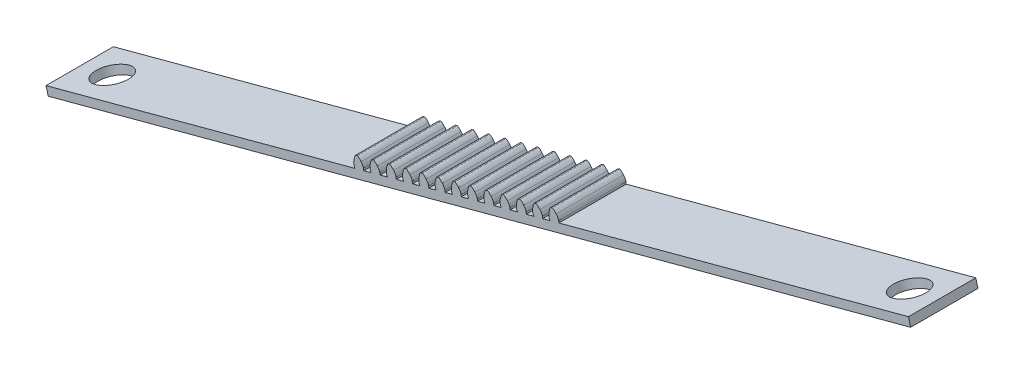
from build123d import *

# Parameters (mm, degrees)
BOSS_EXTRUDE1_DEPTH = 25.4
SKETCH2_W           = 25.4
SKETCH2_H           = 3.175
BOSS_EXTRUDE2_DEPTH = 57.15
SKETCH3_W           = 25.4
SKETCH3_H           = 3.175
BOSS_EXTRUDE3_DEPTH = 53.975
SKETCH4_R           = 6.35
CUT_EXTRUDE3_DEPTH  = 25.4
SKETCH5_R           = 6.35
CUT_EXTRUDE4_DEPTH  = 10


with BuildPart() as part:
    # Sketch1 → Boss-Extrude1 (new body)
    with BuildSketch(Plane.XY):
        Polygon((44.647261736, 20.714486461), (-13.352958173, 5.173374375), (-16.689028233, 4.279477097), (-15.867277765, 1.212662598), (202.166329374, 59.634591554), (201.344578906, 62.701406052), (121.586879759, 41.330394976), (118.2508097, 40.436497698), (115.453250762, 39.68689404), (112.117180703, 38.792996761), (109.319621765, 38.043393103), (105.983551706, 37.149495825), (103.185992768, 36.399892167), (99.849922709, 35.505994888), (97.052363772, 34.75639123), (93.716293712, 33.862493952), (90.918734775, 33.112890294), (87.582664715, 32.218993016), (84.785105778, 31.469389357), (81.449035718, 30.575492079), (78.651476781, 29.825888421), (75.315406721, 28.931991143), (72.517847784, 28.182387485), (69.181777724, 27.288490206), (66.384218787, 26.538886548), (63.048148727, 25.64498927), (60.25058979, 24.895385612), (56.91451973, 24.001488334), (54.116960793, 23.251884675), (50.780890733, 22.357987397), (47.983331796, 21.608383739), align=None)
        with BuildLine():
            Line((44.348064563, 21.379688114), (44.647261736, 20.714486461))
            Line((44.647261736, 20.714486461), (47.983331796, 21.608383739))
            Line((47.983331796, 21.608383739), (47.909843322, 22.334063856))
            add(Edge.make_bspline(
                [(47.909843322, 22.334063856), (47.656461382, 23.298010334), (46.99176643, 24.051815986)],
                knots=[0, 0, 0, 1, 1, 1], degree=2))
            add(Edge.make_bspline(
                [(46.99176643, 24.051815986), (46.671641431, 24.436486873), (46.198202162, 24.922805329), (45.688546167, 25.305711494), (45.505990595, 25.264278727)],
                knots=[0, 0, 0, 0, 0.77483603, 1, 1, 1, 1], degree=3))
            Line((45.505990595, 25.264278727), (44.964754656, 25.119254995))
            add(Edge.make_bspline(
                [(44.28426641, 23.326343542), (44.369167347, 23.819540802), (44.536018554, 24.477424573), (44.78594051, 25.063859037), (44.964754656, 25.119254995)],
                knots=[0, 0, 0, 0, 0.77483603, 1, 1, 1, 1], degree=3))
            add(Edge.make_bspline(
                [(44.348064563, 21.379688114), (44.085526521, 22.341181222), (44.28426641, 23.326343542)],
                knots=[0, 0, 0, 1, 1, 1], degree=2))
        make_face()
        with BuildLine():
            Line((50.48169356, 23.02318905), (50.780890733, 22.357987397))
            Line((50.780890733, 22.357987397), (54.116960793, 23.251884675))
            Line((54.116960793, 23.251884675), (54.043472319, 23.977564792))
            add(Edge.make_bspline(
                [(54.043472319, 23.977564792), (53.790090379, 24.94151127), (53.125395427, 25.695316922)],
                knots=[0, 0, 0, 1, 1, 1], degree=2))
            add(Edge.make_bspline(
                [(53.125395427, 25.695316922), (52.805270428, 26.079987809), (52.331831159, 26.566306265), (51.822175164, 26.949212431), (51.639619592, 26.907779664)],
                knots=[0, 0, 0, 0, 0.77483603, 1, 1, 1, 1], degree=3))
            Line((51.639619592, 26.907779664), (51.098383653, 26.762755931))
            add(Edge.make_bspline(
                [(50.417895407, 24.969844478), (50.502796344, 25.463041738), (50.669647551, 26.12092551), (50.919569507, 26.707359974), (51.098383653, 26.762755931)],
                knots=[0, 0, 0, 0, 0.77483603, 1, 1, 1, 1], degree=3))
            add(Edge.make_bspline(
                [(50.48169356, 23.02318905), (50.219155518, 23.984682158), (50.417895407, 24.969844478)],
                knots=[0, 0, 0, 1, 1, 1], degree=2))
        make_face()
        with BuildLine():
            Line((118.2508097, 40.436497698), (121.586879759, 41.330394976))
            Line((121.586879759, 41.330394976), (121.513391285, 42.056075093))
            add(Edge.make_bspline(
                [(121.513391285, 42.056075093), (121.260009346, 43.020021571), (120.595314393, 43.773827223)],
                knots=[0, 0, 0, 1, 1, 1], degree=2))
            add(Edge.make_bspline(
                [(120.595314393, 43.773827223), (120.275189395, 44.15849811), (119.801750125, 44.644816566), (119.29209413, 45.027722731), (119.109538558, 44.986289964)],
                knots=[0, 0, 0, 0, 0.77483603, 1, 1, 1, 1], degree=3))
            Line((119.109538558, 44.986289964), (118.568302619, 44.841266231))
            add(Edge.make_bspline(
                [(117.887814373, 43.048354779), (117.972715311, 43.541552038), (118.139566517, 44.19943581), (118.389488473, 44.785870274), (118.568302619, 44.841266231)],
                knots=[0, 0, 0, 0, 0.77483603, 1, 1, 1, 1], degree=3))
            add(Edge.make_bspline(
                [(117.951612527, 41.101699351), (117.689074484, 42.063192458), (117.887814373, 43.048354779)],
                knots=[0, 0, 0, 1, 1, 1], degree=2))
            Line((117.951612527, 41.101699351), (118.2508097, 40.436497698))
        make_face()
        with BuildLine():
            Line((56.615322557, 24.666689987), (56.91451973, 24.001488334))
            Line((56.91451973, 24.001488334), (60.25058979, 24.895385612))
            Line((60.25058979, 24.895385612), (60.177101316, 25.621065729))
            add(Edge.make_bspline(
                [(60.177101316, 25.621065729), (59.923719376, 26.585012207), (59.259024424, 27.338817859)],
                knots=[0, 0, 0, 1, 1, 1], degree=2))
            add(Edge.make_bspline(
                [(59.259024424, 27.338817859), (58.938899425, 27.723488746), (58.465460156, 28.209807202), (57.955804161, 28.592713367), (57.773248589, 28.5512806)],
                knots=[0, 0, 0, 0, 0.77483603, 1, 1, 1, 1], degree=3))
            Line((57.773248589, 28.5512806), (57.23201265, 28.406256867))
            add(Edge.make_bspline(
                [(56.551524404, 26.613345415), (56.636425341, 27.106542674), (56.803276548, 27.764426446), (57.053198504, 28.35086091), (57.23201265, 28.406256867)],
                knots=[0, 0, 0, 0, 0.77483603, 1, 1, 1, 1], degree=3))
            add(Edge.make_bspline(
                [(56.615322557, 24.666689987), (56.352784515, 25.628183094), (56.551524404, 26.613345415)],
                knots=[0, 0, 0, 1, 1, 1], degree=2))
        make_face()
        with BuildLine():
            Line((112.117180703, 38.792996761), (115.453250762, 39.68689404))
            Line((115.453250762, 39.686894039), (115.379762288, 40.412574156))
            add(Edge.make_bspline(
                [(115.379762288, 40.412574156), (115.126380349, 41.376520634), (114.461685396, 42.130326286)],
                knots=[0, 0, 0, 1, 1, 1], degree=2))
            add(Edge.make_bspline(
                [(114.461685396, 42.130326286), (114.141560398, 42.514997173), (113.668121128, 43.001315629), (113.158465133, 43.384221795), (112.975909561, 43.342789028)],
                knots=[0, 0, 0, 0, 0.77483603, 1, 1, 1, 1], degree=3))
            Line((112.975909561, 43.342789028), (112.434673622, 43.197765295))
            add(Edge.make_bspline(
                [(111.754185376, 41.404853842), (111.839086314, 41.898051102), (112.00593752, 42.555934874), (112.255859476, 43.142369338), (112.434673622, 43.197765295)],
                knots=[0, 0, 0, 0, 0.77483603, 1, 1, 1, 1], degree=3))
            add(Edge.make_bspline(
                [(111.81798353, 39.458198414), (111.555445487, 40.419691522), (111.754185376, 41.404853842)],
                knots=[0, 0, 0, 1, 1, 1], degree=2))
            Line((111.81798353, 39.458198414), (112.117180703, 38.792996761))
        make_face()
        with BuildLine():
            Line((62.748951554, 26.310190923), (63.048148727, 25.64498927))
            Line((63.048148727, 25.64498927), (66.384218787, 26.538886548))
            Line((66.384218787, 26.538886548), (66.310730313, 27.264566665))
            add(Edge.make_bspline(
                [(66.310730313, 27.264566665), (66.057348373, 28.228513143), (65.392653421, 28.982318795)],
                knots=[0, 0, 0, 1, 1, 1], degree=2))
            add(Edge.make_bspline(
                [(65.392653421, 28.982318795), (65.072528422, 29.366989682), (64.599089153, 29.853308138), (64.089433158, 30.236214303), (63.906877586, 30.194781536)],
                knots=[0, 0, 0, 0, 0.77483603, 1, 1, 1, 1], degree=3))
            Line((63.906877586, 30.194781536), (63.365641647, 30.049757804))
            add(Edge.make_bspline(
                [(62.685153401, 28.256846351), (62.770054338, 28.750043611), (62.936905545, 29.407927383), (63.186827501, 29.994361847), (63.365641647, 30.049757804)],
                knots=[0, 0, 0, 0, 0.77483603, 1, 1, 1, 1], degree=3))
            add(Edge.make_bspline(
                [(62.748951554, 26.310190923), (62.486413512, 27.271684031), (62.685153401, 28.256846351)],
                knots=[0, 0, 0, 1, 1, 1], degree=2))
        make_face()
        with BuildLine():
            Line((105.983551706, 37.149495825), (109.319621765, 38.043393103))
            Line((109.319621765, 38.043393103), (109.246133292, 38.76907322))
            add(Edge.make_bspline(
                [(109.246133292, 38.76907322), (108.992751352, 39.733019698), (108.328056399, 40.48682535)],
                knots=[0, 0, 0, 1, 1, 1], degree=2))
            add(Edge.make_bspline(
                [(108.328056399, 40.48682535), (108.007931401, 40.871496237), (107.534492131, 41.357814693), (107.024836136, 41.740720858), (106.842280564, 41.699288091)],
                knots=[0, 0, 0, 0, 0.77483603, 1, 1, 1, 1], degree=3))
            Line((106.842280564, 41.699288091), (106.301044626, 41.554264359))
            add(Edge.make_bspline(
                [(105.620556379, 39.761352906), (105.705457317, 40.254550166), (105.872308523, 40.912433937), (106.122230479, 41.498868401), (106.301044626, 41.554264359)],
                knots=[0, 0, 0, 0, 0.77483603, 1, 1, 1, 1], degree=3))
            add(Edge.make_bspline(
                [(105.684354533, 37.814697478), (105.42181649, 38.776190586), (105.620556379, 39.761352906)],
                knots=[0, 0, 0, 1, 1, 1], degree=2))
            Line((105.684354533, 37.814697478), (105.983551706, 37.149495825))
        make_face()
        with BuildLine():
            Line((68.882580551, 27.953691859), (69.181777724, 27.288490206))
            Line((69.181777724, 27.288490206), (72.517847784, 28.182387485))
            Line((72.517847784, 28.182387485), (72.44435931, 28.908067601))
            add(Edge.make_bspline(
                [(72.44435931, 28.908067601), (72.19097737, 29.87201408), (71.526282418, 30.625819731)],
                knots=[0, 0, 0, 1, 1, 1], degree=2))
            add(Edge.make_bspline(
                [(71.526282418, 30.625819731), (71.206157419, 31.010490619), (70.73271815, 31.496809074), (70.223062155, 31.87971524), (70.040506583, 31.838282473)],
                knots=[0, 0, 0, 0, 0.77483603, 1, 1, 1, 1], degree=3))
            Line((70.040506583, 31.838282473), (69.499270644, 31.69325874))
            add(Edge.make_bspline(
                [(68.818782397, 29.900347287), (68.903683335, 30.393544547), (69.070534542, 31.051428319), (69.320456498, 31.637862783), (69.499270644, 31.69325874)],
                knots=[0, 0, 0, 0, 0.77483603, 1, 1, 1, 1], degree=3))
            add(Edge.make_bspline(
                [(68.882580551, 27.953691859), (68.620042509, 28.915184967), (68.818782397, 29.900347287)],
                knots=[0, 0, 0, 1, 1, 1], degree=2))
        make_face()
        with BuildLine():
            Line((99.849922709, 35.505994888), (103.185992768, 36.399892167))
            Line((103.185992768, 36.399892167), (103.112504295, 37.125572283))
            add(Edge.make_bspline(
                [(103.112504295, 37.125572283), (102.859122355, 38.089518762), (102.194427402, 38.843324413)],
                knots=[0, 0, 0, 1, 1, 1], degree=2))
            add(Edge.make_bspline(
                [(102.194427402, 38.843324413), (101.874302404, 39.227995301), (101.400863134, 39.714313756), (100.891207139, 40.097219922), (100.708651567, 40.055787155)],
                knots=[0, 0, 0, 0, 0.77483603, 1, 1, 1, 1], degree=3))
            Line((100.708651567, 40.055787155), (100.167415629, 39.910763422))
            add(Edge.make_bspline(
                [(99.486927382, 38.117851969), (99.57182832, 38.611049229), (99.738679526, 39.268933001), (99.988601482, 39.855367465), (100.167415629, 39.910763422)],
                knots=[0, 0, 0, 0, 0.77483603, 1, 1, 1, 1], degree=3))
            add(Edge.make_bspline(
                [(99.550725536, 36.171196541), (99.288187493, 37.132689649), (99.486927382, 38.117851969)],
                knots=[0, 0, 0, 1, 1, 1], degree=2))
            Line((99.550725536, 36.171196541), (99.849922709, 35.505994888))
        make_face()
        with BuildLine():
            Line((75.016209548, 29.597192796), (75.315406721, 28.931991143))
            Line((75.315406721, 28.931991143), (78.651476781, 29.825888421))
            Line((78.651476781, 29.825888421), (78.577988307, 30.551568538))
            add(Edge.make_bspline(
                [(78.577988307, 30.551568538), (78.324606367, 31.515515016), (77.659911415, 32.269320668)],
                knots=[0, 0, 0, 1, 1, 1], degree=2))
            add(Edge.make_bspline(
                [(77.659911415, 32.269320668), (77.339786416, 32.653991555), (76.866347147, 33.140310011), (76.356691152, 33.523216176), (76.17413558, 33.481783409)],
                knots=[0, 0, 0, 0, 0.77483603, 1, 1, 1, 1], degree=3))
            Line((76.17413558, 33.481783409), (75.632899641, 33.336759677))
            add(Edge.make_bspline(
                [(74.952411394, 31.543848224), (75.037312332, 32.037045484), (75.204163539, 32.694929255), (75.454085494, 33.281363719), (75.632899641, 33.336759677)],
                knots=[0, 0, 0, 0, 0.77483603, 1, 1, 1, 1], degree=3))
            add(Edge.make_bspline(
                [(75.016209548, 29.597192796), (74.753671506, 30.558685904), (74.952411394, 31.543848224)],
                knots=[0, 0, 0, 1, 1, 1], degree=2))
        make_face()
        with BuildLine():
            Line((93.716293712, 33.862493952), (97.052363772, 34.75639123))
            Line((97.052363772, 34.75639123), (96.978875298, 35.482071347))
            add(Edge.make_bspline(
                [(96.978875298, 35.482071347), (96.725493358, 36.446017825), (96.060798405, 37.199823477)],
                knots=[0, 0, 0, 1, 1, 1], degree=2))
            add(Edge.make_bspline(
                [(96.060798405, 37.199823477), (95.740673407, 37.584494364), (95.267234137, 38.07081282), (94.757578143, 38.453718985), (94.575022571, 38.412286218)],
                knots=[0, 0, 0, 0, 0.77483603, 1, 1, 1, 1], degree=3))
            Line((94.575022571, 38.412286218), (94.033786632, 38.267262486))
            add(Edge.make_bspline(
                [(93.353298385, 36.474351033), (93.438199323, 36.967548293), (93.605050529, 37.625432065), (93.854972485, 38.211866529), (94.033786632, 38.267262486)],
                knots=[0, 0, 0, 0, 0.77483603, 1, 1, 1, 1], degree=3))
            add(Edge.make_bspline(
                [(93.417096539, 34.527695605), (93.154558496, 35.489188713), (93.353298385, 36.474351033)],
                knots=[0, 0, 0, 1, 1, 1], degree=2))
            Line((93.417096539, 34.527695605), (93.716293712, 33.862493952))
        make_face()
        with BuildLine():
            Line((81.149838545, 31.240693732), (81.449035718, 30.575492079))
            Line((81.449035718, 30.575492079), (84.785105778, 31.469389357))
            Line((84.785105778, 31.469389357), (84.711617304, 32.195069474))
            add(Edge.make_bspline(
                [(84.711617304, 32.195069474), (84.458235364, 33.159015952), (83.793540411, 33.912821604)],
                knots=[0, 0, 0, 1, 1, 1], degree=2))
            add(Edge.make_bspline(
                [(83.793540411, 33.912821604), (83.473415413, 34.297492491), (82.999976143, 34.783810947), (82.490320149, 35.166717113), (82.307764577, 35.125284346)],
                knots=[0, 0, 0, 0, 0.77483603, 1, 1, 1, 1], degree=3))
            Line((82.307764577, 35.125284346), (81.766528638, 34.980260613))
            add(Edge.make_bspline(
                [(81.086040391, 33.18734916), (81.170941329, 33.68054642), (81.337792535, 34.338430192), (81.587714491, 34.924864656), (81.766528638, 34.980260613)],
                knots=[0, 0, 0, 0, 0.77483603, 1, 1, 1, 1], degree=3))
            add(Edge.make_bspline(
                [(81.149838545, 31.240693732), (80.887300503, 32.20218684), (81.086040391, 33.18734916)],
                knots=[0, 0, 0, 1, 1, 1], degree=2))
        make_face()
        with BuildLine():
            Line((87.582664715, 32.218993016), (90.918734775, 33.112890294))
            Line((90.918734775, 33.112890294), (90.845246301, 33.838570411))
            add(Edge.make_bspline(
                [(90.845246301, 33.838570411), (90.591864361, 34.802516889), (89.927169408, 35.556322541)],
                knots=[0, 0, 0, 1, 1, 1], degree=2))
            add(Edge.make_bspline(
                [(89.927169408, 35.556322541), (89.60704441, 35.940993428), (89.13360514, 36.427311884), (88.623949146, 36.810218049), (88.441393574, 36.768785282)],
                knots=[0, 0, 0, 0, 0.77483603, 1, 1, 1, 1], degree=3))
            Line((88.441393574, 36.768785282), (87.900157635, 36.623761549))
            add(Edge.make_bspline(
                [(87.219669388, 34.830850097), (87.304570326, 35.324047356), (87.471421532, 35.981931128), (87.721343488, 36.568365592), (87.900157635, 36.623761549)],
                knots=[0, 0, 0, 0, 0.77483603, 1, 1, 1, 1], degree=3))
            add(Edge.make_bspline(
                [(87.283467542, 32.884194669), (87.020929499, 33.845687776), (87.219669388, 34.830850097)],
                knots=[0, 0, 0, 1, 1, 1], degree=2))
            Line((87.283467542, 32.884194669), (87.582664715, 32.218993016))
        make_face()
    extrude(amount=BOSS_EXTRUDE1_DEPTH)

    # Sketch2 → Boss-Extrude2 (add)
    with BuildSketch(Plane(origin=(-14.501206049, -3.88558645, 0), x_dir=(0, 0, 1), z_dir=(-0.965925826, -0.258819045, 0))):
        with Locations((12.7, 6.865595802)):
            Rectangle(SKETCH2_W, SKETCH2_H)
    extrude(amount=BOSS_EXTRUDE2_DEPTH)

    # Sketch3 → Boss-Extrude3 (add)
    with BuildSketch(Plane(origin=(203.53240109, 54.536342506, 0), x_dir=(0, 0, -1), z_dir=(0.965925826, 0.258819045, 0))):
        with Locations((-12.7, 6.865595802)):
            Rectangle(SKETCH3_W, SKETCH3_H)
    extrude(amount=BOSS_EXTRUDE3_DEPTH)

    # Sketch4 → Cut-Extrude3 (cut)
    with BuildSketch(Plane(origin=(-2.187822184, 8.165063547, 0), x_dir=(0.965925826, 0.258819045, 0), z_dir=(-0.258819045, 0.965925826, 0))):
        with Locations((-59.46275321, -12.7)):
            Circle(SKETCH4_R)
    extrude(amount=-CUT_EXTRUDE3_DEPTH, mode=Mode.SUBTRACT)

    # Sketch5 → Cut-Extrude4 (cut)
    with BuildSketch(Plane(origin=(-2.187822184, 8.165063547, 0), x_dir=(0.965925826, 0.258819045, 0), z_dir=(-0.258819045, 0.965925826, 0))):
        with Locations((251.98724679, -12.7)):
            Circle(SKETCH5_R)
    extrude(amount=-CUT_EXTRUDE4_DEPTH, mode=Mode.SUBTRACT)


solid = part.part
